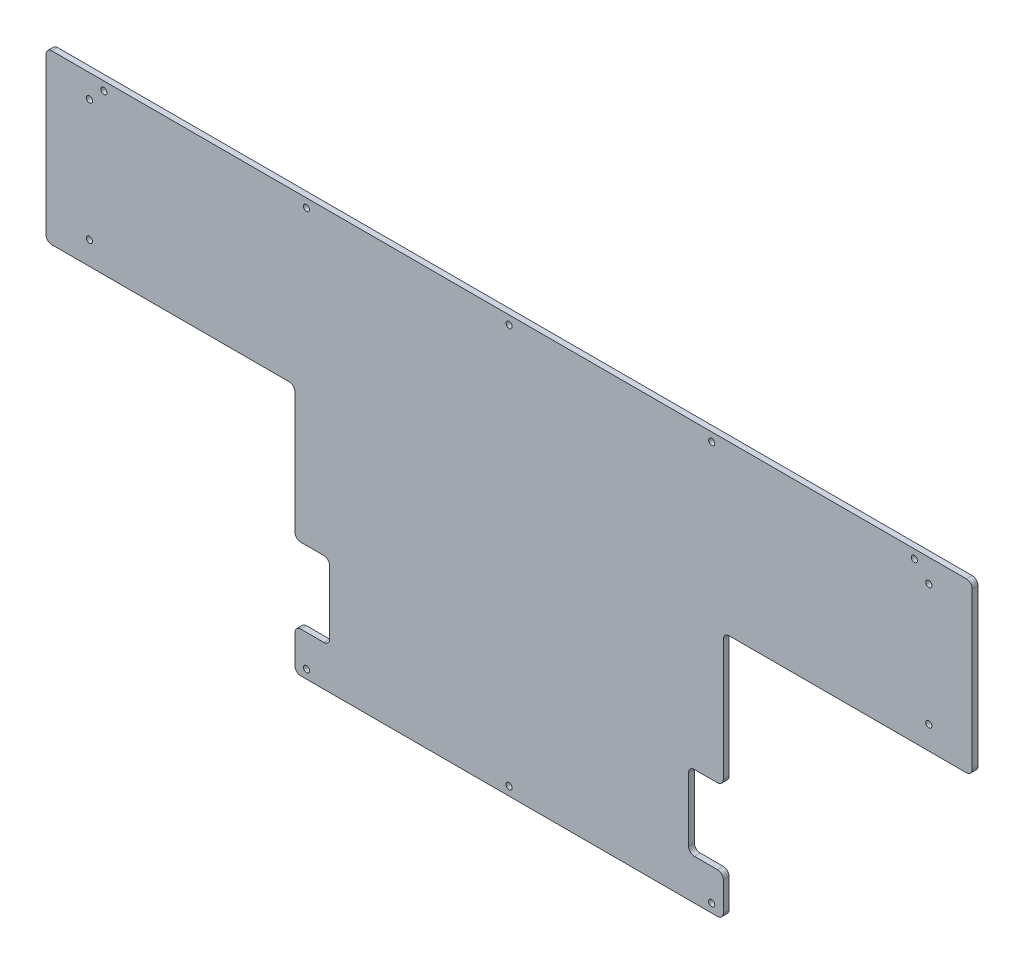
from build123d import *

# Parameters (mm, degrees)
BOSS_EXTRUDE1_DEPTH = 6.35
SKETCH2_R           = 3.3655
CUT_EXTRUDE1_DEPTH  = 7.35
SKETCH3_R           = 3.3655
CUT_EXTRUDE2_DEPTH  = 7.35
SKETCH5_W           = 38.1
SKETCH5_H           = 82.55
CUT_EXTRUDE3_DEPTH  = 7.35
FILLET1_R           = 6.35


with BuildPart() as part:
    # Sketch1 → Boss-Extrude1 (new body)
    with BuildSketch(Plane.XY):
        Polygon((-508, 0), (508, 0), (508, -184.15), (234.95, -184.15), (234.95, -457.2), (-234.95, -457.2), (-234.95, -184.15), (-508, -184.15), align=None)
    extrude(amount=BOSS_EXTRUDE1_DEPTH)

    # Sketch2 → Cut-Extrude1 (cut, through all)
    with BuildSketch(Plane.XY.offset(6.35)):
        with Locations((0, -9.525)):
            Circle(SKETCH2_R)
        with Locations((0, -447.675)):
            Circle(SKETCH2_R)
        with Locations((222.25, -9.525)):
            Circle(SKETCH2_R)
        with Locations((222.25, -447.675)):
            Circle(SKETCH2_R)
        with Locations((444.5, -9.525)):
            Circle(SKETCH2_R)
        with Locations((-222.25, -9.525)):
            Circle(SKETCH2_R)
        with Locations((-222.25, -447.675)):
            Circle(SKETCH2_R)
        with Locations((-444.5, -9.525)):
            Circle(SKETCH2_R)
    extrude(amount=-CUT_EXTRUDE1_DEPTH, mode=Mode.SUBTRACT)

    # Sketch3 → Cut-Extrude2 (cut, through all)
    with BuildSketch(Plane.XY.offset(6.35)):
        with Locations((-460.375, -25.4)):
            Circle(SKETCH3_R)
        with Locations((-460.375, -158.75)):
            Circle(SKETCH3_R)
    cut_extrude2 = extrude(amount=-CUT_EXTRUDE2_DEPTH, mode=Mode.SUBTRACT)

    # Mirror1: Cut-Extrude2 across plane
    add(cut_extrude2.mirror(Plane(origin=(0, 0, 0), x_dir=(0, 0, 1), z_dir=(1, 0, 0))), mode=Mode.SUBTRACT)

    # Sketch5 → Cut-Extrude3 (cut, through all)
    with BuildSketch(Plane.XY.offset(6.35)):
        with Locations((-215.9, -371.475)):
            Rectangle(SKETCH5_W, SKETCH5_H)
    cut_extrude3 = extrude(amount=-CUT_EXTRUDE3_DEPTH, mode=Mode.SUBTRACT)

    # Mirror2: Cut-Extrude3 across plane
    add(cut_extrude3.mirror(Plane(origin=(0, 0, 0), x_dir=(0, 0, 1), z_dir=(1, 0, 0))), mode=Mode.SUBTRACT)

    # Fillet1
    fillet1_edges = [part.edges().sort_by_distance(p)[0] for p in [
        (234.95, -330.2, 3.175),
        (234.95, -412.75, 3.175),
        (196.85, -412.75, 3.175),
        (196.85, -330.2, 3.175),
        (-508, 0, 3.175),
        (508, 0, 3.175),
        (508, -184.15, 3.175),
        (234.95, -184.15, 3.175),
        (234.95, -457.2, 3.175),
        (-234.95, -457.2, 3.175),
        (-234.95, -184.15, 3.175),
        (-508, -184.15, 3.175),
        (-234.95, -412.75, 3.175),
        (-234.95, -330.2, 3.175),
        (-196.85, -330.2, 3.175),
        (-196.85, -412.75, 3.175),
    ]]
    fillet(fillet1_edges, radius=FILLET1_R)


solid = part.part
